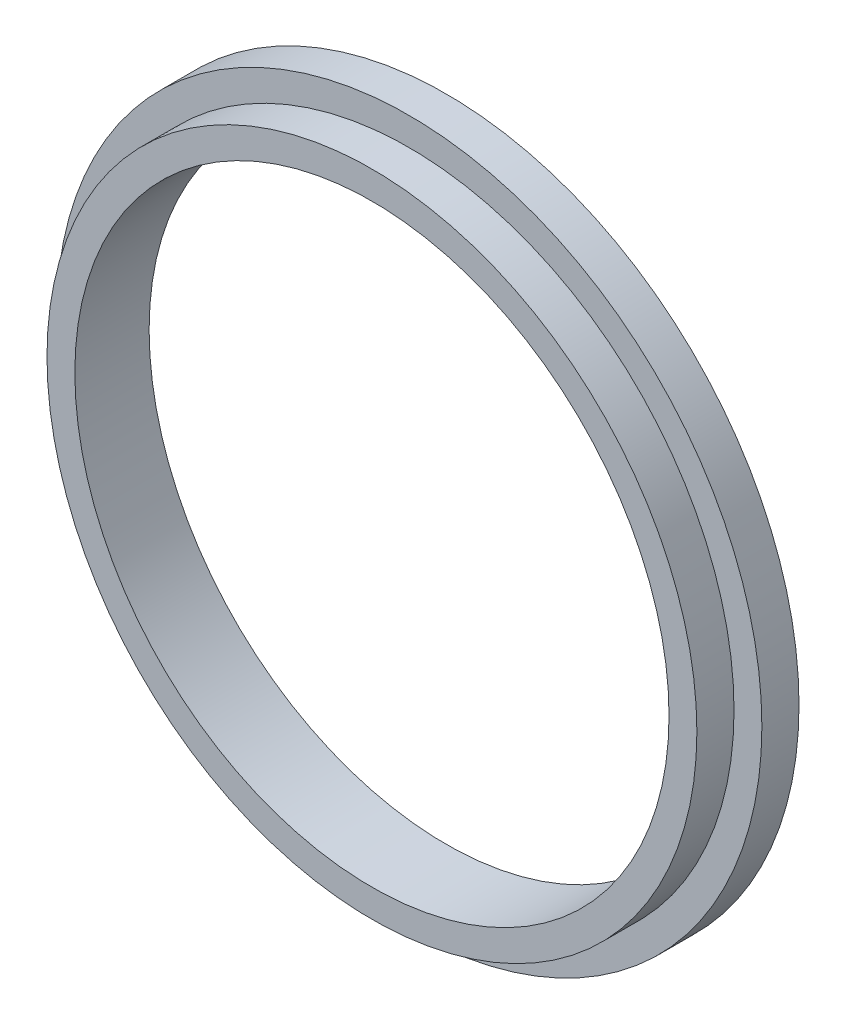
from build123d import *

# Parameters (mm, degrees)
SKETCH1_R           = 190
SKETCH1_R_2         = 160
BOSS_EXTRUDE1_DEPTH = 20
SKETCH2_R           = 175
SKETCH2_R_2         = 160
BOSS_EXTRUDE2_DEPTH = 20


with BuildPart() as part:
    # Sketch1 → Boss-Extrude1 (new body)
    with BuildSketch(Plane.XY):
        Circle(SKETCH1_R)
        Circle(SKETCH1_R_2, mode=Mode.SUBTRACT)
    extrude(amount=BOSS_EXTRUDE1_DEPTH)

    # Sketch2 → Boss-Extrude2 (add)
    with BuildSketch(Plane.XY.offset(20)):
        Circle(SKETCH2_R)
        Circle(SKETCH2_R_2, mode=Mode.SUBTRACT)
    extrude(amount=BOSS_EXTRUDE2_DEPTH)


solid = part.part
